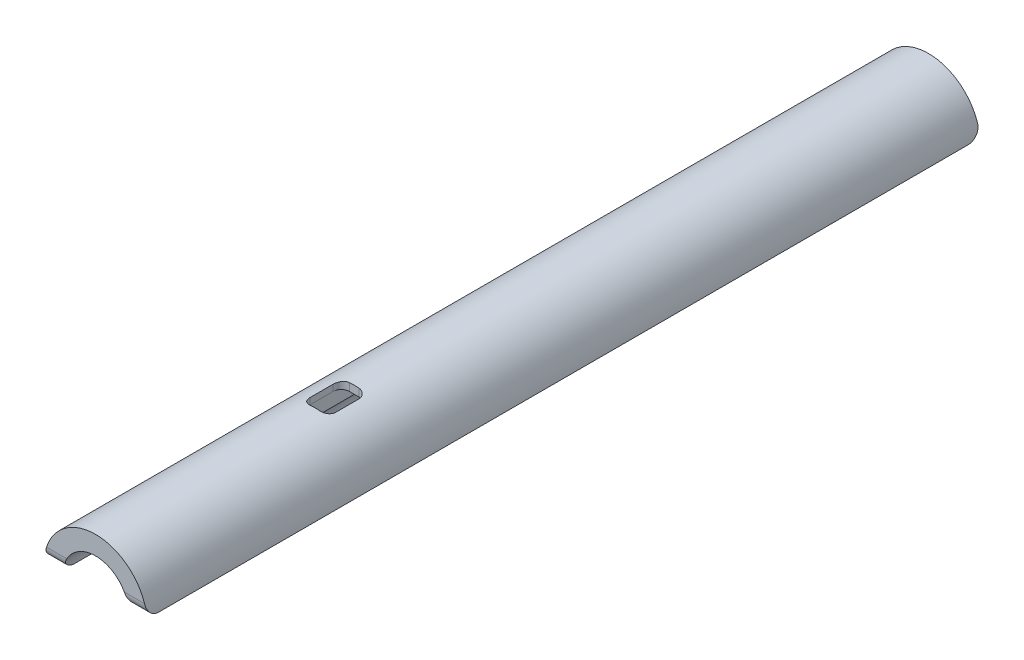
from build123d import *

# Parameters (mm, degrees)
BOSS_EXTRUDE1_DEPTH = 519.5
FILLET1_R           = 15
SKETCH2_W           = 33
SKETCH2_H           = 202
CUT_EXTRUDE1_DEPTH  = 54.5
FILLET2_R           = 10
CUT_EXTRUDE2_DEPTH  = 60.3400001


with BuildPart() as part:
    # Sketch1 → Boss-Extrude1 (new body, symmetric)
    with BuildSketch(Plane.XY):
        with BuildLine():
            Line((-40.754430434, 5), (-64.145425402, 5))
            ThreePointArc((-64.145425402, 5), (0, 64.34), (64.145425402, 5))
            Line((64.145425402, 5), (40.754430434, 5))
            ThreePointArc((40.754430434, 5), (0, 41.06), (-40.754430434, 5))
        make_face()
    extrude(amount=BOSS_EXTRUDE1_DEPTH, both=True)

    # Fillet1
    fillet1_edges = [part.edges().sort_by_distance(p)[0] for p in [
        (-52.449927918, 5, 519.5),
        (-52.449927918, 5, -519.5),
        (52.449927918, 5, -519.5),
        (52.449927918, 5, 519.5),
    ]]
    fillet(fillet1_edges, radius=FILLET1_R)

    # Sketch2 → Cut-Extrude1 (cut)
    with BuildSketch(Plane(origin=(0, 0, 0), x_dir=(1, 0, 0), z_dir=(0, 1, 0))):
        with Locations((0, -163)):
            Rectangle(SKETCH2_W, SKETCH2_H)
    extrude(amount=CUT_EXTRUDE1_DEPTH, mode=Mode.SUBTRACT)

    # Fillet2
    fillet2_edges = [part.edges().sort_by_distance(p)[0] for p in [
        (-16.5, 46.049425523, 62),
        (-16.5, 46.049425523, 264),
        (16.5, 46.049425523, 264),
        (16.5, 46.049425523, 62),
    ]]
    fillet(fillet2_edges, radius=FILLET2_R)

    # Sketch3 → Cut-Extrude2 (cut, through all)
    with BuildSketch(Plane.XZ.offset(-5)):
        with BuildLine():
            Line((-5.999925402, 246), (6.000074598, 246))
            ThreePointArc((6.000074598, 246), (13.07114241, 243.071067812), (16.000074598, 236))
            Line((16.000074598, 236), (16.000074598, 207))
            ThreePointArc((16.000074598, 207), (13.07114241, 199.928932188), (6.000074598, 197))
            Line((6.000074598, 197), (-5.999925402, 197))
            ThreePointArc((-5.999925402, 197), (-13.070993214, 199.928932188), (-15.999925402, 207))
            Line((-15.999925402, 207), (-15.999925402, 236))
            ThreePointArc((-15.999925402, 236), (-13.070993214, 243.071067812), (-5.999925402, 246))
        make_face()
    extrude(amount=-CUT_EXTRUDE2_DEPTH, mode=Mode.SUBTRACT)


solid = part.part
